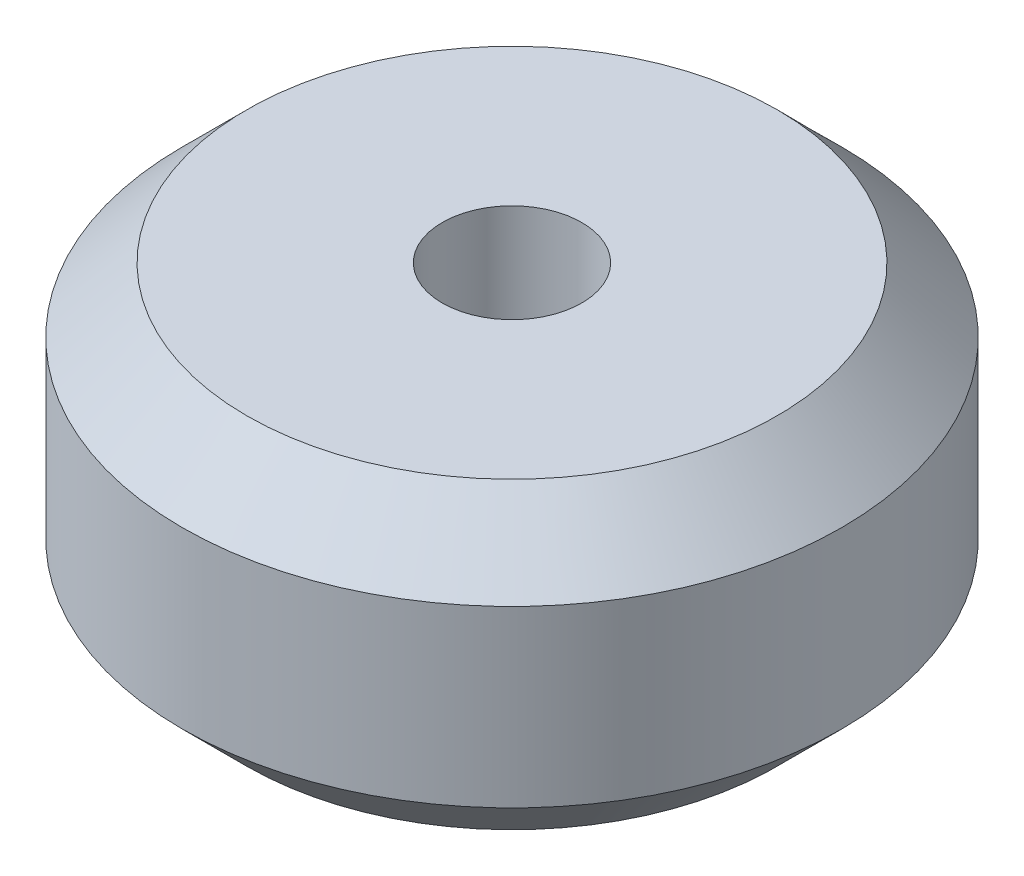
from build123d import *


with BuildPart() as part:
    # Sketch1 → Revolve1 (revolve)
    with BuildSketch(Plane.XY):
        Polygon((2.54, 5.5245), (2.54, -5.5245), (9.652, -5.5245), (12.0015, -3.175), (12.0015, 3.175), (9.652, 5.5245), align=None)
    revolve(axis=Axis((0, 5.5245, 0), (0, -1, 0)))


solid = part.part
